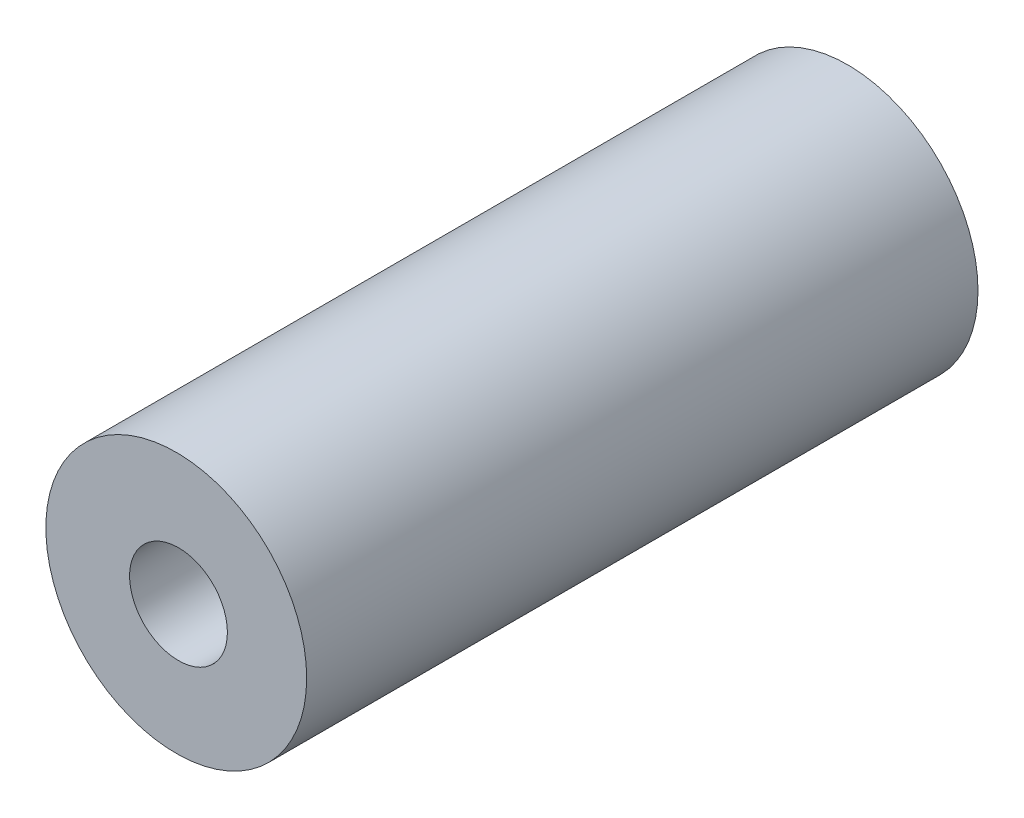
from build123d import *

# Parameters (mm, degrees)
ESQUISSE1_R        = 4
ESQUISSE1_R_2      = 1.5
BOSS_EXTRU_1_DEPTH = 20.59


with BuildPart() as part:
    # Esquisse1 → Boss.-Extru.1 (new body)
    with BuildSketch(Plane.XY):
        with Locations((-0.068563305, 0)):
            Circle(ESQUISSE1_R)
        Circle(ESQUISSE1_R_2, mode=Mode.SUBTRACT)
    extrude(amount=BOSS_EXTRU_1_DEPTH)


solid = part.part
